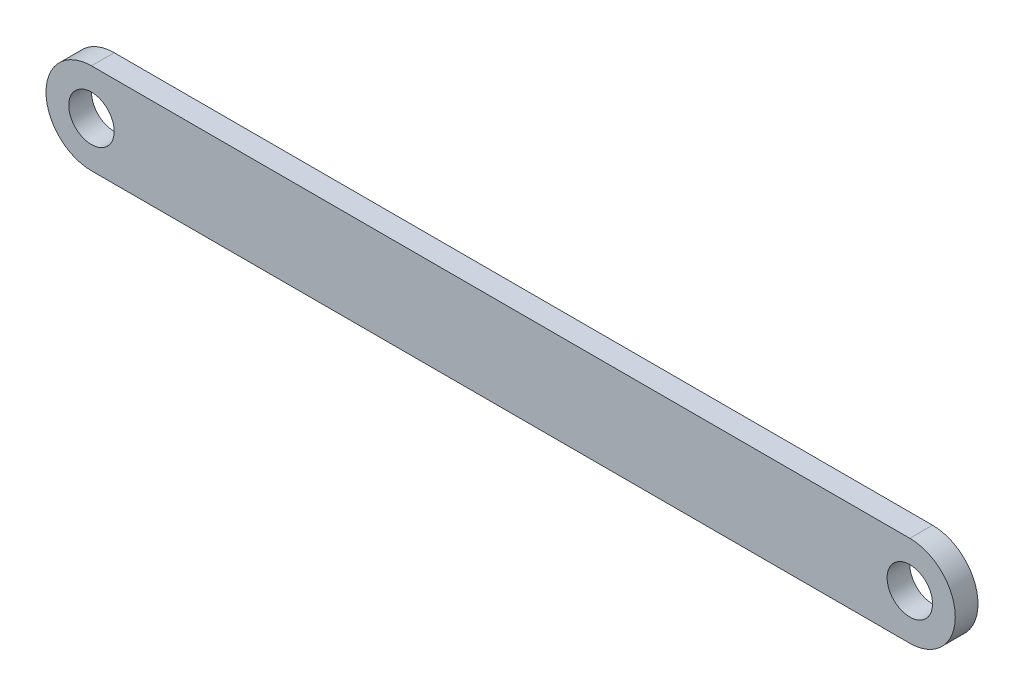
from build123d import *

# Parameters (mm, degrees)
SKETCH1_R           = 3.175
BOSS_EXTRUDE2_DEPTH = 3.175


with BuildPart() as part:
    # Sketch1 → Boss-Extrude2 (new body)
    with BuildSketch(Plane.XY):
        with BuildLine():
            Line((-57.15, 6.35), (57.15, 6.35))
            ThreePointArc((57.15, 6.35), (63.5, 0), (57.15, -6.35))
            Line((57.15, -6.35), (-57.15, -6.35))
            ThreePointArc((-57.15, -6.35), (-63.5, 0), (-57.15, 6.35))
        make_face()
        with Locations((-57.15, 0)):
            Circle(SKETCH1_R, mode=Mode.SUBTRACT)
        with Locations((57.15, 0)):
            Circle(SKETCH1_R, mode=Mode.SUBTRACT)
    extrude(amount=BOSS_EXTRUDE2_DEPTH)


solid = part.part
